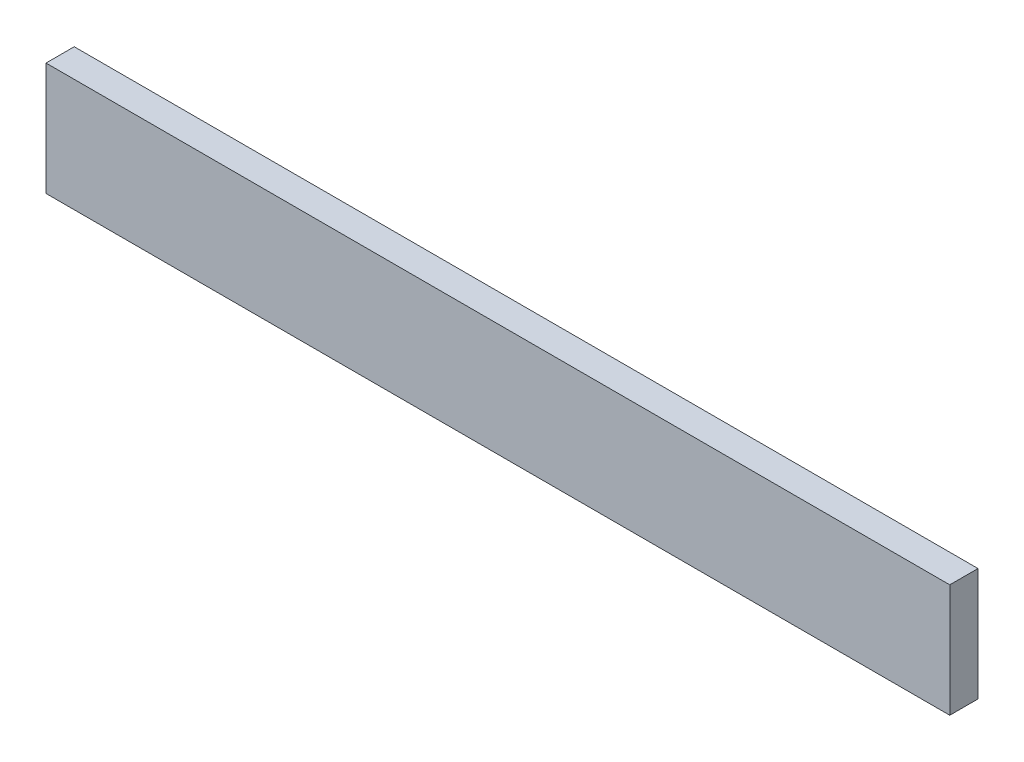
from build123d import *

# Parameters (mm, degrees)
SKETCH1_W           = 800
SKETCH1_H           = 100
BOSS_EXTRUDE1_DEPTH = 25


with BuildPart() as part:
    # Sketch1 → Boss-Extrude1 (new body)
    with BuildSketch(Plane.XY):
        with Locations((400, 50)):
            Rectangle(SKETCH1_W, SKETCH1_H)
    extrude(amount=BOSS_EXTRUDE1_DEPTH)


solid = part.part
